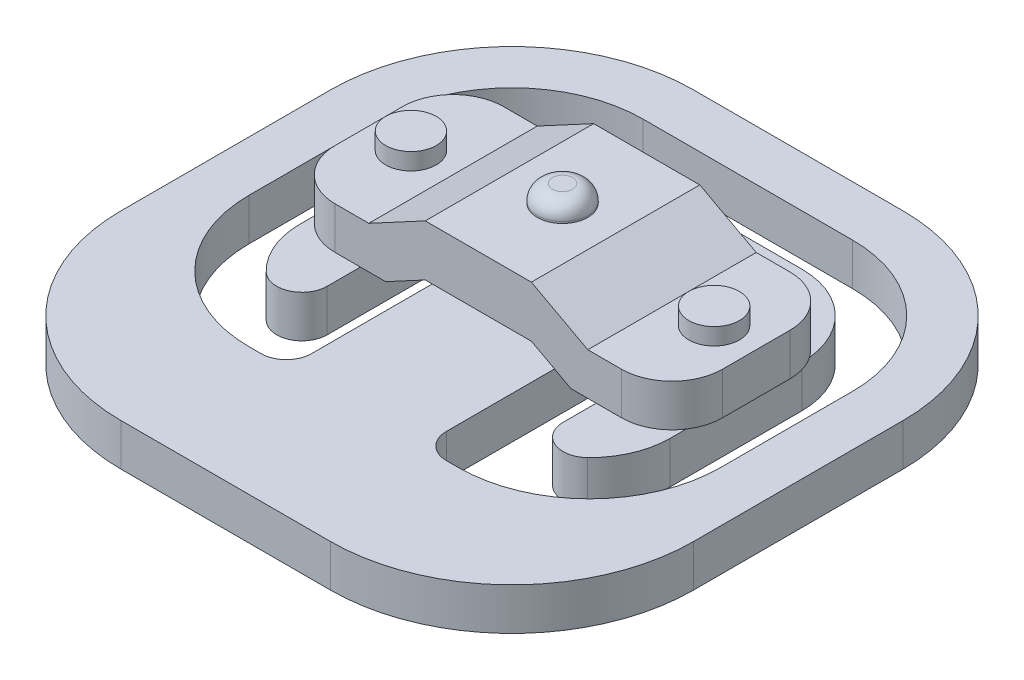
from build123d import *

# Parameters (mm, degrees)
BOSS_EXTRUDE1_DEPTH = 2.5
CUT_EXTRUDE1_DEPTH  = 3.5
BOSS_EXTRUDE2_DEPTH = 4.3
CUT_EXTRUDE2_DEPTH  = 20
SKETCH5_R           = 1.5
BOSS_EXTRUDE3_DEPTH = 1
SKETCH6_R           = 1.5
BOSS_EXTRUDE4_DEPTH = 1
FILLET1_R           = 0.9


with BuildPart() as part:
    # Sketch1 → Boss-Extrude1 (new body)
    with BuildSketch(Plane(origin=(0, 0, 0), x_dir=(1, 0, 0), z_dir=(0, 1, 0))):
        with BuildLine():
            Line((-6.212908396, -17), (6.212908396, -17))
            ThreePointArc((6.212908396, -17), (13.840534019, -13.840534019), (17, -6.212908396))
            Line((17, -6.212908396), (17, 6.212908396))
            ThreePointArc((17, 6.212908396), (13.840534019, 13.840534019), (6.212908396, 17))
            Line((6.212908396, 17), (-6.212908396, 17))
            ThreePointArc((-6.212908396, 17), (-13.840534019, 13.840534019), (-17, 6.212908396))
            Line((-17, 6.212908396), (-17, -6.212908396))
            ThreePointArc((-17, -6.212908396), (-13.840534019, -13.840534019), (-6.212908396, -17))
        make_face()
    extrude(amount=BOSS_EXTRUDE1_DEPTH)

    # Sketch2 → Cut-Extrude1 (cut, through all)
    with BuildSketch(Plane(origin=(0, 2.5, 0), x_dir=(1, 0, 0), z_dir=(0, 1, 0))):
        with BuildLine():
            Line((5.4, 3.7), (5.6, 3.7))
            ThreePointArc((5.6, 3.7), (6.589949494, 3.289949494), (7, 2.3))
            Line((7, 2.3), (7, -3.972202362))
            ThreePointArc((7, -3.972202362), (7.915239118, -5.353525898), (9.544072948, -5.049194321))
            ThreePointArc((9.544072948, -5.049194321), (10.621026492, -3.477336416), (11, -1.61))
            Line((11, -1.61), (11, 6.212908396))
            ThreePointArc((11, 6.212908396), (9.597893331, 9.597893331), (6.212908396, 11))
            Line((6.212908396, 11), (-6.212908396, 11))
            ThreePointArc((-6.212908396, 11), (-9.597893331, 9.597893331), (-11, 6.212908396))
            Line((-11, 6.212908396), (-11, -1.61))
            ThreePointArc((-11, -1.61), (-10.621026492, -3.477336416), (-9.544072948, -5.049194321))
            ThreePointArc((-9.544072948, -5.049194321), (-7.915239118, -5.353525898), (-7, -3.972202362))
            Line((-7, -3.972202362), (-7, 2.3))
            ThreePointArc((-7, 2.3), (-6.589949494, 3.289949494), (-5.6, 3.7))
            Line((-5.6, 3.7), (-5.4, 3.7))
            ThreePointArc((-5.4, 3.7), (-4.410050506, 3.289949494), (-4, 2.3))
            Line((-4, 2.3), (-4, -7.9))
            ThreePointArc((-4, -7.9), (-4.439339828, -8.960660172), (-5.5, -9.4))
            Line((-5.5, -9.4), (-6.21, -9.4))
            ThreePointArc((-6.21, -9.4), (-11.718361825, -7.118361825), (-14, -1.61))
            Line((-14, -1.61), (-14, 6.212908396))
            ThreePointArc((-14, 6.212908396), (-11.719213675, 11.719213675), (-6.212908396, 14))
            Line((-6.212908396, 14), (6.212908396, 14))
            ThreePointArc((6.212908396, 14), (11.719213675, 11.719213675), (14, 6.212908396))
            Line((14, 6.212908396), (14, -1.61))
            ThreePointArc((14, -1.61), (11.718361825, -7.118361825), (6.21, -9.4))
            Line((6.21, -9.4), (5.5, -9.4))
            ThreePointArc((5.5, -9.4), (4.439339828, -8.960660172), (4, -7.9))
            Line((4, -7.9), (4, 2.3))
            ThreePointArc((4, 2.3), (4.410050506, 3.289949494), (5.4, 3.7))
        make_face()
    extrude(amount=-CUT_EXTRUDE1_DEPTH, mode=Mode.SUBTRACT)

    # Sketch3 → Boss-Extrude2 (add)
    with BuildSketch(Plane(origin=(0, 2.5, 0), x_dir=(1, 0, 0), z_dir=(0, 1, 0))):
        with BuildLine():
            Line((-8.5, 8), (8.5, 8))
            ThreePointArc((8.5, 8), (10.621320344, 7.121320344), (11.5, 5))
            Line((11.5, 5), (11.5, 1))
            ThreePointArc((11.5, 1), (10.621320344, -1.121320344), (8.5, -2))
            Line((8.5, -2), (-8.5, -2))
            ThreePointArc((-8.5, -2), (-10.621320344, -1.121320344), (-11.5, 1))
            Line((-11.5, 1), (-11.5, 5))
            ThreePointArc((-11.5, 5), (-10.621320344, 7.121320344), (-8.5, 8))
        make_face()
    extrude(amount=BOSS_EXTRUDE2_DEPTH)

    # Sketch4 → Cut-Extrude2 (cut, through all)
    with BuildSketch(Plane.XY.offset(2)):
        Polygon((-11.5, 5), (-6.5, 5), (-3.15, 6.8), (3.15, 6.8), (6.5, 5), (11.5, 5), (14.66460311, 7.657087543), (13.998030241, 12.878575014), (-15.83110563, 15.267127793), (-17.386442324, 7.657087543), align=None)
        Polygon((3.15, 3.762686567), (-3.15, 3.762686567), (-5.5, 2.5), (5.5, 2.5), align=None)
    extrude(amount=-CUT_EXTRUDE2_DEPTH, mode=Mode.SUBTRACT)

    # Sketch5 → Boss-Extrude3 (add)
    with BuildSketch(Plane(origin=(0, 5, 0), x_dir=(1, 0, 0), z_dir=(0, 1, 0))):
        with Locations((9, 3)):
            Circle(SKETCH5_R)
    boss_extrude3 = extrude(amount=BOSS_EXTRUDE3_DEPTH)

    # Mirror1: Boss-Extrude3 across plane
    add(boss_extrude3.mirror(Plane(origin=(0, 0, 0), x_dir=(0, 0, 1), z_dir=(1, 0, 0))))

    # Sketch6 → Boss-Extrude4 (add)
    with BuildSketch(Plane(origin=(0, 6.8, 0), x_dir=(1, 0, 0), z_dir=(0, 1, 0))):
        with Locations((0, 3)):
            Circle(SKETCH6_R)
    extrude(amount=BOSS_EXTRUDE4_DEPTH)

    # Fillet1
    fillet1_edges = [part.edges().sort_by_distance(p)[0] for p in [
        (-1.5, 7.8, -3),
    ]]
    fillet(fillet1_edges, radius=FILLET1_R)


solid = part.part
